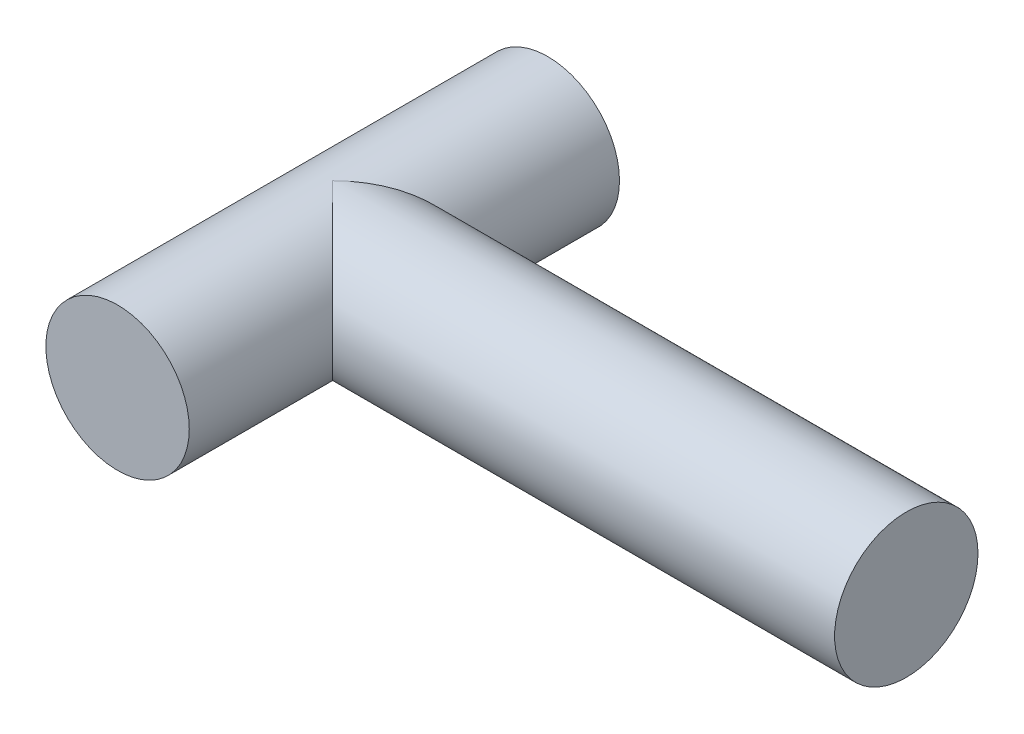
from build123d import *

# Parameters (mm, degrees)
SKETCH1_R           = 7.5
BOSS_EXTRUDE1_DEPTH = 22.5
SKETCH2_R           = 7.5
BOSS_EXTRUDE2_DEPTH = 60


with BuildPart() as part:
    # Sketch1 → Boss-Extrude1 (new body, symmetric)
    with BuildSketch(Plane.XY):
        Circle(SKETCH1_R)
    extrude(amount=BOSS_EXTRUDE1_DEPTH, both=True)

    # Sketch2 → Boss-Extrude2 (add)
    with BuildSketch(Plane(origin=(0, 0, 0), x_dir=(0, 0, -1), z_dir=(1, 0, 0))):
        Circle(SKETCH2_R)
    extrude(amount=BOSS_EXTRUDE2_DEPTH)


solid = part.part
